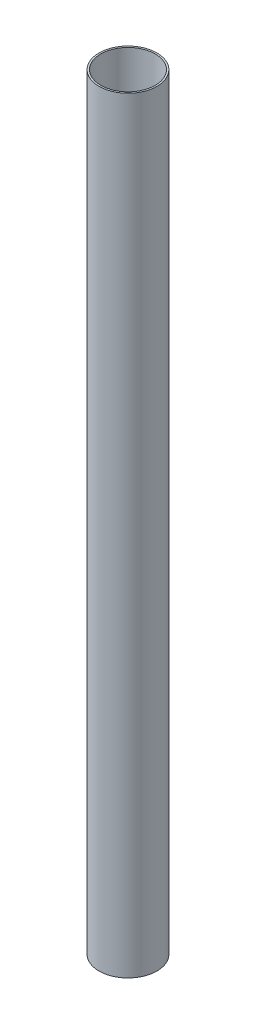
from build123d import *

# Parameters (mm, degrees)
SKETCH_1_R      = 17
SKETCH_1_R_2    = 16
EXTRUDE_1_DEPTH = 450


with BuildPart() as part:
    # Эскиз1 → Бобышка-Вытянуть1 (new body)
    with BuildSketch(Plane(origin=(0, 0, 0), x_dir=(1, 0, 0), z_dir=(0, 1, 0))):
        Circle(SKETCH_1_R)
        Circle(SKETCH_1_R_2, mode=Mode.SUBTRACT)
    extrude(amount=EXTRUDE_1_DEPTH)


solid = part.part
